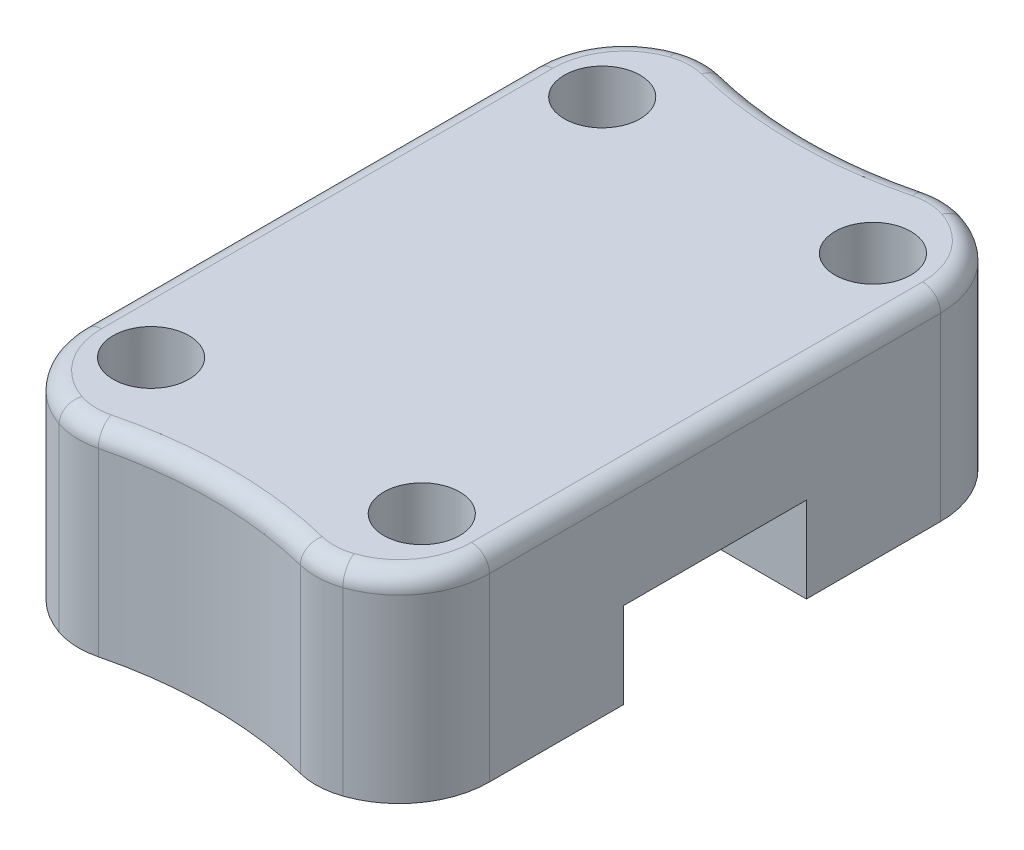
from build123d import *

# Parameters (mm, degrees)
SKETCH1_W               = 45
SKETCH1_H               = 70
BOSS_EXTRUDE1_DEPTH     = 22
SKETCH2_W               = 20.25
SKETCH2_H               = 9.5
CUT_EXTRUDE1_DEPTH      = 1
CUT_EXTRUDE1_DEPTH_BACK = 46
SKETCH3_R               = 4.2
CUT_EXTRUDE2_DEPTH      = 23
FILLET1_R               = 10
CUT_EXTRUDE3_DEPTH      = 23
FILLET2_R               = 8
FILLET4_R               = 2
CHAMFER1_SIZE           = 0.5
CHAMFER1_SIZE2          = 1.37373871
CHAMFER1_PART_2_SIZE    = 0.5
CHAMFER1_PART_2_SIZE2   = 1.37373871


with BuildPart() as part:
    # Sketch1 → Boss-Extrude1 (new body)
    with BuildSketch(Plane(origin=(0, 0, 0), x_dir=(1, 0, 0), z_dir=(0, 1, 0))):
        Rectangle(SKETCH1_W, SKETCH1_H)
    extrude(amount=BOSS_EXTRUDE1_DEPTH)

    # Sketch2 → Cut-Extrude1 (cut, two sides)
    with BuildSketch(Plane(origin=(22.5, 0, 0), x_dir=(0, 0, -1), z_dir=(1, 0, 0))) as cut_extrude1_sk:
        with Locations((0, 4.75)):
            Rectangle(SKETCH2_W, SKETCH2_H)
    extrude(amount=CUT_EXTRUDE1_DEPTH, mode=Mode.SUBTRACT)
    extrude(cut_extrude1_sk.sketch, amount=-CUT_EXTRUDE1_DEPTH_BACK, mode=Mode.SUBTRACT)

    # Sketch3 → Cut-Extrude2 (cut, through all)
    with BuildSketch(Plane.XZ):
        with Locations((15, 25)):
            Circle(SKETCH3_R)
        with Locations((15, -25)):
            Circle(SKETCH3_R)
        with Locations((-15, -25)):
            Circle(SKETCH3_R)
        with Locations((-15, 25)):
            Circle(SKETCH3_R)
    extrude(amount=-CUT_EXTRUDE2_DEPTH, mode=Mode.SUBTRACT)

    # Fillet1
    fillet1_edges = [part.edges().sort_by_distance(p)[0] for p in [
        (-22.5, 11, -35),
        (22.5, 11, -35),
        (22.5, 11, 35),
        (-22.5, 11, 35),
    ]]
    fillet(fillet1_edges, radius=FILLET1_R)

    # Sketch6 → Cut-Extrude3 (cut, through all)
    with BuildSketch(Plane.XZ):
        with BuildLine():
            Line((12.5, 35), (-12.5, 35))
            ThreePointArc((-12.5, 35), (0, 33.26906369), (12.5, 35))
        make_face()
        with BuildLine():
            Line((12.5, -35), (-12.5, -35))
            ThreePointArc((-12.5, -35), (0, -33.26906369), (12.5, -35))
        make_face()
    extrude(amount=-CUT_EXTRUDE3_DEPTH, mode=Mode.SUBTRACT)

    # Fillet2
    fillet2_edges = [part.edges().sort_by_distance(p)[0] for p in [
        (12.5, 11, 35),
        (-12.5, 11, 35),
        (12.5, 11, -35),
        (-12.5, 11, -35),
    ]]
    fillet(fillet2_edges, radius=FILLET2_R)

    # Fillet4
    fillet4_edges = [part.edges().sort_by_distance(p)[0] for p in [
        (-22.5, 22, 0),
        (22.5, 22, 0),
        (20.63102045, 22, -30.821211768),
        (-20.63102045, 22, 30.821211768),
        (0, 22, 33.26906369),
        (20.63102045, 22, 30.821211768),
        (0, 22, -33.26906369),
        (-20.63102045, 22, -30.821211768),
        (13.473401565, 22, -34.886533438),
        (-13.473401565, 22, -34.886533438),
        (-13.473401565, 22, 34.886533438),
        (13.473401565, 22, 34.886533438),
    ]]
    fillet(fillet4_edges, radius=FILLET4_R)

    # Chamfer1
    chamfer1_edges = [part.edges().sort_by_distance(p)[0] for p in [
        (-19.2, 0, -25),
        (10.8, 0, -25),
    ]]
    chamfer1_side = [part.faces().sort_by_distance(p)[0] for p in [
        (0, 0, -21.437561791),
    ]]
    chamfer(chamfer1_edges, length=CHAMFER1_SIZE, length2=CHAMFER1_SIZE2, reference=chamfer1_side[0])

    # Chamfer1 part 2
    chamfer1_part_2_edges = [part.edges().sort_by_distance(p)[0] for p in [
        (-19.2, 0, 25),
        (10.8, 0, 25),
    ]]
    chamfer1_part_2_side = [part.faces().sort_by_distance(p)[0] for p in [
        (0, 0, 21.437561791),
    ]]
    chamfer(chamfer1_part_2_edges, length=CHAMFER1_PART_2_SIZE, length2=CHAMFER1_PART_2_SIZE2, reference=chamfer1_part_2_side[0])


solid = part.part
